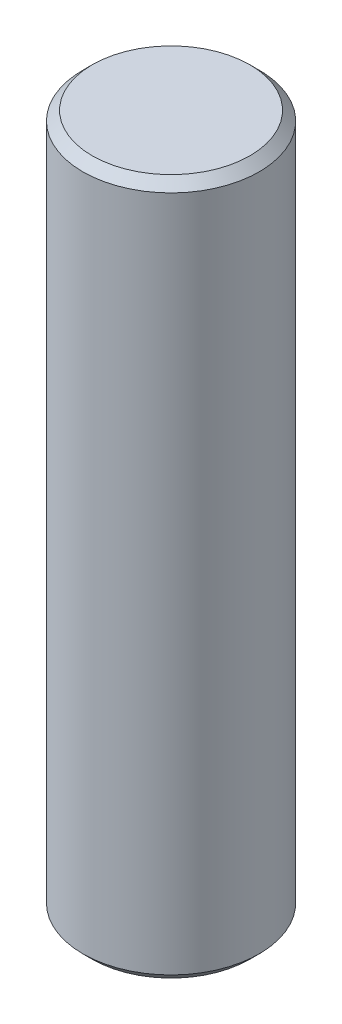
from build123d import *

# Parameters (mm, degrees)
SKETCH2_R           = 4.826
BOSS_EXTRUDE1_DEPTH = 19.05
CHAMFER1_SIZE       = 0.508


with BuildPart() as part:
    # Sketch2 → Boss-Extrude1 (new body, symmetric)
    with BuildSketch(Plane(origin=(0, 0, 0), x_dir=(1, 0, 0), z_dir=(0, 1, 0))):
        Circle(SKETCH2_R)
    extrude(amount=BOSS_EXTRUDE1_DEPTH, both=True)

    # Chamfer1
    chamfer1_edges = [part.edges().sort_by_distance(p)[0] for p in [
        (-4.826, -19.05, 0),
        (-4.826, 19.05, 0),
    ]]
    chamfer(chamfer1_edges, length=CHAMFER1_SIZE)


solid = part.part
